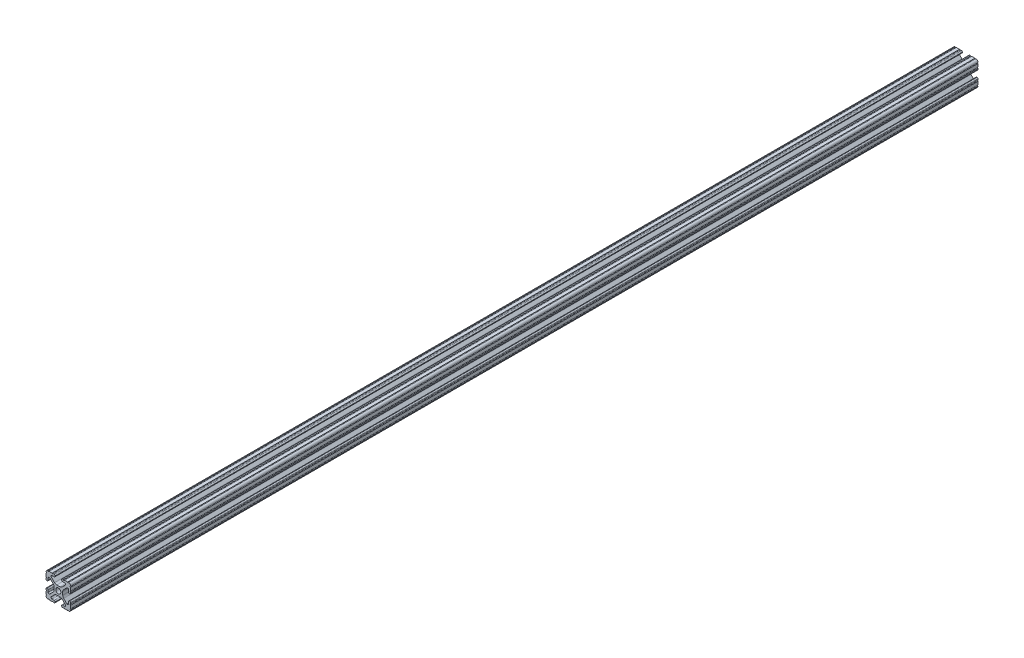
from build123d import *

# Parameters (mm, degrees)
SKETCH1_R               = 2.6035
BOSS_EXTRUDE1_DEPTH     = 466.725
SKETCH2_R               = 3.175
CUT_EXTRUDE1_DEPTH      = 9.1915
CUT_EXTRUDE1_DEPTH_BACK = 18.2085


with BuildPart() as part:
    # Sketch1 → Boss-Extrude1 (new body, symmetric)
    with BuildSketch(Plane.XY):
        with BuildLine():
            Line((-7.179650497, -8.645192506), (-3.952270251, -5.423690499))
            ThreePointArc((-3.952270251, -5.423690499), (-2.922936451, -4.736929036), (-1.709253557, -4.4958))
            Line((-1.709253557, -4.4958), (1.709253557, -4.4958))
            ThreePointArc((1.709253557, -4.4958), (2.922936451, -4.736929036), (3.952270251, -5.423690499))
            Line((3.952270251, -5.423690499), (7.179650497, -8.645192506))
            ThreePointArc((7.179650497, -8.645192506), (7.41473083, -9.822813117), (6.416408329, -10.4902))
            Line((6.416408329, -10.4902), (4.287512407, -10.4902))
            ThreePointArc((4.287512407, -10.4902), (3.54574862, -10.79744862), (3.2385, -11.539212407))
            Line((3.2385, -11.539212407), (3.2385, -11.650987593))
            ThreePointArc((3.2385, -11.650987593), (3.54574862, -12.39275138), (4.287512407, -12.7))
            Line((4.287512407, -12.7), (5.317126718, -12.7))
            ThreePointArc((5.317126718, -12.7), (5.825126718, -12.192), (6.333126718, -12.7))
            Line((6.333126718, -12.7), (9.550443118, -12.7))
            ThreePointArc((9.550443118, -12.7), (10.058366869, -12.192000006), (10.566443095, -12.699847501))
            ThreePointArc((10.566443095, -12.699847501), (12.082537762, -12.08250727), (12.699846982, -10.566399977))
            ThreePointArc((12.699846982, -10.566399977), (12.192000006, -10.058323491), (12.7, -9.5504))
            Line((12.7, -9.5504), (12.7, -6.3330836))
            ThreePointArc((12.7, -6.3330836), (12.192, -5.8250836), (12.7, -5.3170836))
            Line((12.7, -5.3170836), (12.7, -4.287469289))
            ThreePointArc((12.7, -4.287469289), (12.39275138, -3.545705502), (11.650987593, -3.238456882))
            Line((11.650987593, -3.238456882), (11.539212407, -3.238456882))
            ThreePointArc((11.539212407, -3.238456882), (10.79744862, -3.545705502), (10.4902, -4.287469289))
            Line((10.4902, -4.287469289), (10.4902, -6.402089023))
            ThreePointArc((10.4902, -6.402089023), (9.856505071, -7.351067942), (8.737131347, -7.129408934))
            Line((8.737131347, -7.129408934), (5.441005833, -3.840816462))
            ThreePointArc((5.441005833, -3.840816462), (4.750877967, -2.809883091), (4.5085, -1.593185507))
            Line((4.5085, -1.593185507), (4.5085, 1.593185507))
            ThreePointArc((4.5085, 1.593185507), (4.750877967, 2.809883091), (5.441005833, 3.840816462))
            Line((5.441005833, 3.840816462), (8.737131347, 7.129408934))
            ThreePointArc((8.737131347, 7.129408934), (9.856505071, 7.351067942), (10.4902, 6.402089023))
            Line((10.4902, 6.402089023), (10.4902, 4.287469289))
            ThreePointArc((10.4902, 4.287469289), (10.79744862, 3.545705502), (11.539212407, 3.238456882))
            Line((11.539212407, 3.238456882), (11.650987593, 3.238456882))
            ThreePointArc((11.650987593, 3.238456882), (12.39275138, 3.545705502), (12.7, 4.287469289))
            Line((12.7, 4.287469289), (12.7, 5.3170836))
            ThreePointArc((12.7, 5.3170836), (12.192, 5.8250836), (12.7, 6.3330836))
            Line((12.7, 6.3330836), (12.7, 9.5504))
            ThreePointArc((12.7, 9.5504), (12.192000006, 10.058323491), (12.699846982, 10.566399977))
            ThreePointArc((12.699846982, 10.566399977), (12.082537762, 12.08250727), (10.566443095, 12.699847501))
            ThreePointArc((10.566443095, 12.699847501), (10.058366869, 12.192000006), (9.550443118, 12.7))
            Line((9.550443118, 12.7), (6.333126718, 12.7))
            ThreePointArc((6.333126718, 12.7), (5.825126718, 12.192), (5.317126718, 12.7))
            Line((5.317126718, 12.7), (4.287512407, 12.7))
            ThreePointArc((4.287512407, 12.7), (3.54574862, 12.39275138), (3.2385, 11.650987593))
            Line((3.2385, 11.650987593), (3.2385, 11.539212407))
            ThreePointArc((3.2385, 11.539212407), (3.54574862, 10.79744862), (4.287512407, 10.4902))
            Line((4.287512407, 10.4902), (6.476788598, 10.4902))
            ThreePointArc((6.476788598, 10.4902), (7.432222385, 9.85140422), (7.207036008, 8.724370562))
            Line((7.207036008, 8.724370562), (3.898272566, 5.423169045))
            ThreePointArc((3.898272566, 5.423169045), (2.869120213, 4.736787962), (1.655778399, 4.4958))
            Line((1.655778399, 4.4958), (-1.655778399, 4.4958))
            ThreePointArc((-1.655778399, 4.4958), (-2.869120213, 4.736787962), (-3.898272566, 5.423169045))
            Line((-3.898272566, 5.423169045), (-7.207036008, 8.724370562))
            ThreePointArc((-7.207036008, 8.724370562), (-7.432222385, 9.85140422), (-6.476788598, 10.4902))
            Line((-6.476788598, 10.4902), (-4.287512407, 10.4902))
            ThreePointArc((-4.287512407, 10.4902), (-3.54574862, 10.79744862), (-3.2385, 11.539212407))
            Line((-3.2385, 11.539212407), (-3.2385, 11.650987593))
            ThreePointArc((-3.2385, 11.650987593), (-3.54574862, 12.39275138), (-4.287512407, 12.7))
            Line((-4.287512407, 12.7), (-5.317126718, 12.7))
            ThreePointArc((-5.317126718, 12.7), (-5.825126718, 12.192), (-6.333126718, 12.7))
            Line((-6.333126718, 12.7), (-9.550443118, 12.7))
            ThreePointArc((-9.550443118, 12.7), (-10.058366869, 12.192000006), (-10.566443095, 12.699847501))
            ThreePointArc((-10.566443095, 12.699847501), (-12.082537762, 12.08250727), (-12.699846982, 10.566399977))
            ThreePointArc((-12.699846982, 10.566399977), (-12.192000006, 10.058323491), (-12.7, 9.5504))
            Line((-12.7, 9.5504), (-12.7, 6.3330836))
            ThreePointArc((-12.7, 6.3330836), (-12.192, 5.8250836), (-12.7, 5.3170836))
            Line((-12.7, 5.3170836), (-12.7, 4.287469289))
            ThreePointArc((-12.7, 4.287469289), (-12.39275138, 3.545705502), (-11.650987593, 3.238456882))
            Line((-11.650987593, 3.238456882), (-11.539212407, 3.238456882))
            ThreePointArc((-11.539212407, 3.238456882), (-10.79744862, 3.545705502), (-10.4902, 4.287469289))
            Line((-10.4902, 4.287469289), (-10.4902, 6.402089023))
            ThreePointArc((-10.4902, 6.402089023), (-9.856505071, 7.351067942), (-8.737131347, 7.129408934))
            Line((-8.737131347, 7.129408934), (-5.441005833, 3.840816462))
            ThreePointArc((-5.441005833, 3.840816462), (-4.750877967, 2.809883091), (-4.5085, 1.593185507))
            Line((-4.5085, 1.593185507), (-4.5085, -1.593185507))
            ThreePointArc((-4.5085, -1.593185507), (-4.750877967, -2.809883091), (-5.441005833, -3.840816462))
            Line((-5.441005833, -3.840816462), (-8.737131347, -7.129408934))
            ThreePointArc((-8.737131347, -7.129408934), (-9.856505071, -7.351067942), (-10.4902, -6.402089023))
            Line((-10.4902, -6.402089023), (-10.4902, -4.287469289))
            ThreePointArc((-10.4902, -4.287469289), (-10.79744862, -3.545705502), (-11.539212407, -3.238456882))
            Line((-11.539212407, -3.238456882), (-11.650987593, -3.238456882))
            ThreePointArc((-11.650987593, -3.238456882), (-12.39275138, -3.545705502), (-12.7, -4.287469289))
            Line((-12.7, -4.287469289), (-12.7, -5.3170836))
            ThreePointArc((-12.7, -5.3170836), (-12.192, -5.8250836), (-12.7, -6.3330836))
            Line((-12.7, -6.3330836), (-12.7, -9.5504))
            ThreePointArc((-12.7, -9.5504), (-12.192000006, -10.058323491), (-12.699846982, -10.566399977))
            ThreePointArc((-12.699846982, -10.566399977), (-12.082537762, -12.08250727), (-10.566443095, -12.699847501))
            ThreePointArc((-10.566443095, -12.699847501), (-10.058366869, -12.192000006), (-9.550443118, -12.7))
            Line((-9.550443118, -12.7), (-6.333126718, -12.7))
            ThreePointArc((-6.333126718, -12.7), (-5.825126718, -12.192), (-5.317126718, -12.7))
            Line((-5.317126718, -12.7), (-4.287512407, -12.7))
            ThreePointArc((-4.287512407, -12.7), (-3.54574862, -12.39275138), (-3.2385, -11.650987593))
            Line((-3.2385, -11.650987593), (-3.2385, -11.539212407))
            ThreePointArc((-3.2385, -11.539212407), (-3.54574862, -10.79744862), (-4.287512407, -10.4902))
            Line((-4.287512407, -10.4902), (-6.416408329, -10.4902))
            ThreePointArc((-6.416408329, -10.4902), (-7.41473083, -9.822813117), (-7.179650497, -8.645192506))
        make_face()
        Circle(SKETCH1_R, mode=Mode.SUBTRACT)
    extrude(amount=BOSS_EXTRUDE1_DEPTH, both=True)

    # Sketch2 → Cut-Extrude1 (cut, two sides)
    with BuildSketch(Plane(origin=(4.5085, 0, 0), x_dir=(0, 0, -1), z_dir=(1, 0, 0))) as cut_extrude1_sk:
        with Locations((-358.775, 0)):
            Circle(SKETCH2_R)
        with Locations((358.775, 0)):
            Circle(SKETCH2_R)
        with Locations((-85.725, 0)):
            Circle(SKETCH2_R)
        with Locations((85.725, 0)):
            Circle(SKETCH2_R)
    extrude(amount=CUT_EXTRUDE1_DEPTH, mode=Mode.SUBTRACT)
    extrude(cut_extrude1_sk.sketch, amount=-CUT_EXTRUDE1_DEPTH_BACK, mode=Mode.SUBTRACT)


solid = part.part
